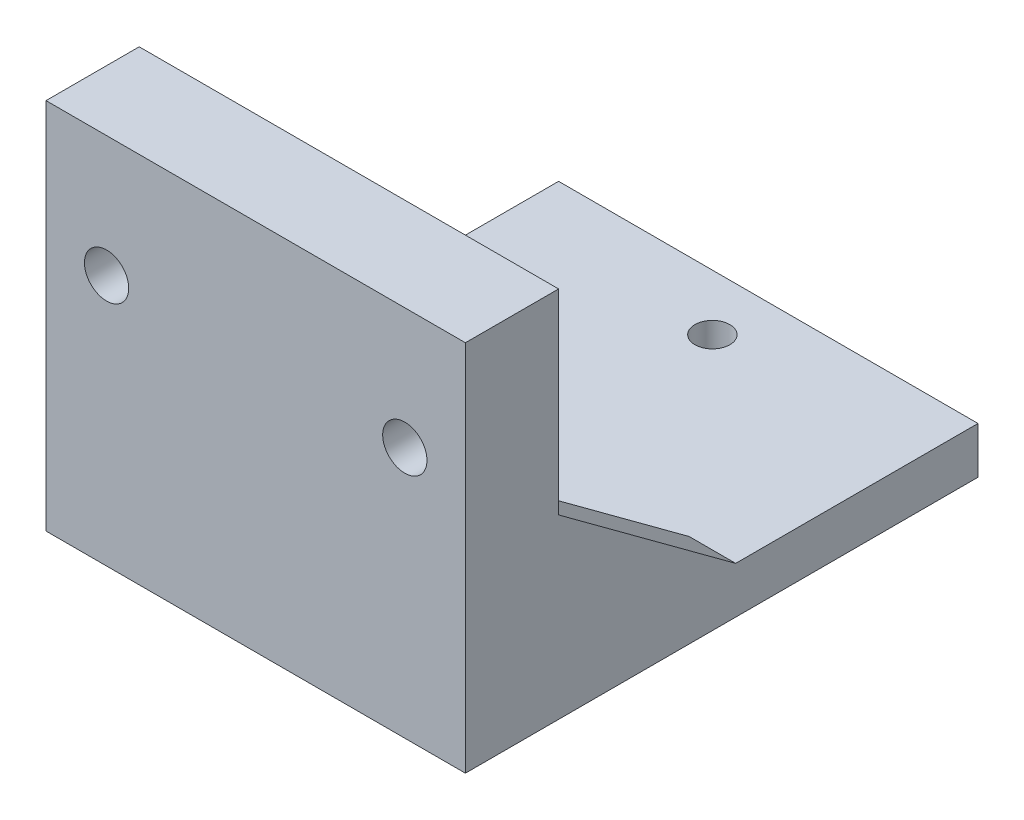
from build123d import *

# Parameters (mm, degrees)
SKETCH7_W                = 45
SKETCH7_H                = 45
SKETCH7_W_2              = 2.024682368
SKETCH7_H_2              = 6.385975888
SKETCH7_R                = 2
SKETCH7_R_2              = 1.875
BOSS_EXTRUDE5_DEPTH      = 5
SKETCH7_3_W              = 45
SKETCH7_3_H              = 2
BOSS_EXTRUDE6_DEPTH      = 40
BOSS_EXTRUDE7_DEPTH      = 5
SKETCH7_4_W              = 45
SKETCH7_4_H              = 8
BOSS_EXTRUDE8_DEPTH      = 40
SKETCH11_R               = 2.375
CUT_EXTRUDE16_DEPTH      = 1
CUT_EXTRUDE16_DEPTH_BACK = 56
SKETCH7_14_R             = 11
CUT_EXTRUDE17_DEPTH      = 1


with BuildPart() as part:
    # Sketch7 → Boss-Extrude5 (new body)
    with BuildSketch(Plane(origin=(0, 0, 0), x_dir=(1, 0, 0), z_dir=(0, 1, 0))):
        with Locations((5.831933892, -118.050969126)):
            Rectangle(SKETCH7_W, SKETCH7_H)
        with Locations((-12.180407292, -119.050969126)):
            Rectangle(SKETCH7_W_2, SKETCH7_H_2, mode=Mode.SUBTRACT)
        with Locations((5.831933892, -136.550969126)):
            Circle(SKETCH7_R, mode=Mode.SUBTRACT)
        with Locations((5.831933892, -101.550969126)):
            Circle(SKETCH7_R_2, mode=Mode.SUBTRACT)
    extrude(amount=BOSS_EXTRUDE5_DEPTH)

    # Sketch7_3 → Boss-Extrude6 (add)
    with BuildSketch(Plane(origin=(0, 0, 0), x_dir=(1, 0, 0), z_dir=(0, 1, 0))):
        with Locations((5.831933892, -141.550969126)):
            Rectangle(SKETCH7_3_W, SKETCH7_3_H)
    extrude(amount=BOSS_EXTRUDE6_DEPTH)

    # Sketch8 → Boss-Extrude7 (add)
    with BuildSketch(Plane.ZY.offset(16.668066108)):
        Polygon((140.550969126, 11), (140.550969126, 5), (121.550969126, 5), (140.550969126, 19), align=None)
    boss_extrude7 = extrude(amount=-BOSS_EXTRUDE7_DEPTH)

    # Mirror2: Boss-Extrude7 across plane
    add(boss_extrude7.mirror(Plane.ZY.offset(-5.831933892)))

    # Sketch7_4 → Boss-Extrude8 (add)
    with BuildSketch(Plane(origin=(0, 0, 0), x_dir=(1, 0, 0), z_dir=(0, 1, 0))):
        with Locations((5.831933892, -146.550969126)):
            Rectangle(SKETCH7_4_W, SKETCH7_4_H)
    extrude(amount=BOSS_EXTRUDE8_DEPTH)

    # Sketch11 → Cut-Extrude16 (cut, two sides)
    with BuildSketch(Plane.XY.offset(150.550969126)) as cut_extrude16_sk:
        with Locations((-10.168066108, 27)):
            Circle(SKETCH11_R)
        with Locations((21.831933892, 27)):
            Circle(SKETCH11_R)
    extrude(amount=CUT_EXTRUDE16_DEPTH, mode=Mode.SUBTRACT)
    extrude(cut_extrude16_sk.sketch, amount=-CUT_EXTRUDE16_DEPTH_BACK, mode=Mode.SUBTRACT)

    # Sketch7_14 → Cut-Extrude17 (cut)
    with BuildSketch(Plane(origin=(0, 0, 0), x_dir=(1, 0, 0), z_dir=(0, 1, 0))):
        with Locations((12.831933892, -119.050969126)):
            Circle(SKETCH7_14_R)
    extrude(amount=CUT_EXTRUDE17_DEPTH, mode=Mode.SUBTRACT)


solid = part.part
